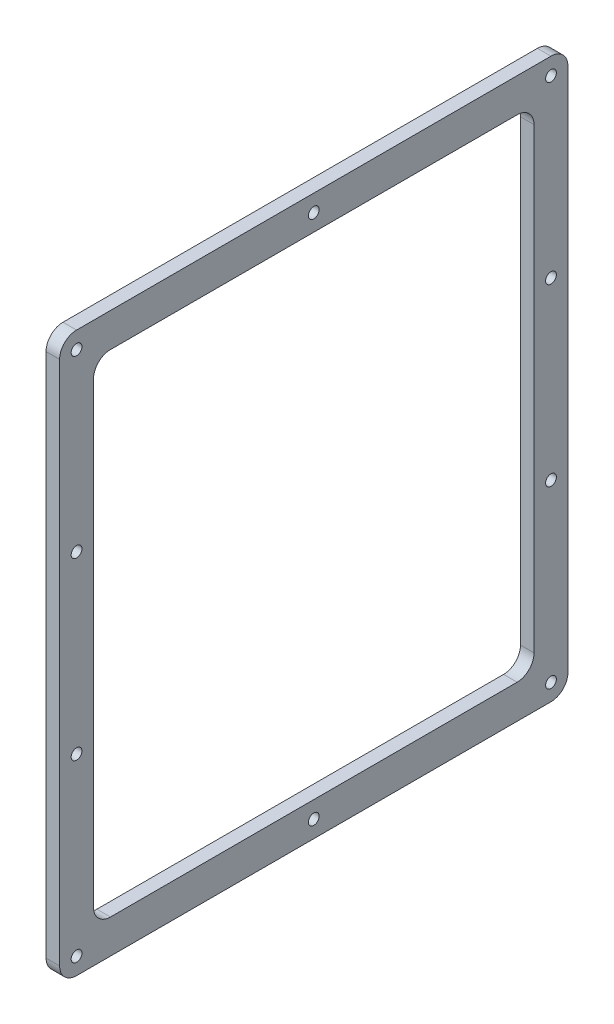
from build123d import *

# Parameters (mm, degrees)
SKETCH1_W              = 190.5
SKETCH1_H              = 209.55
SKETCH1_W_2            = 165.1
SKETCH1_H_2            = 184.15
BOSS_EXTRUDE2_DEPTH    = 5.08
F_10_32_TAPPED_HOLE1_D = 4.0386
FILLET1_R              = 6.35


with BuildPart() as part:
    # Sketch1 → Boss-Extrude2 (new body)
    with BuildSketch(Plane(origin=(0, 0, 0), x_dir=(0, 0, -1), z_dir=(1, 0, 0))):
        with Locations((95.25, 104.775)):
            Rectangle(SKETCH1_W, SKETCH1_H)
        with Locations((95.25, 104.775)):
            Rectangle(SKETCH1_W_2, SKETCH1_H_2, mode=Mode.SUBTRACT)
    extrude(amount=BOSS_EXTRUDE2_DEPTH)

    # #10-32 Tapped Hole1 (through all)
    with Locations(Plane(origin=(5.08, 0, 0), x_dir=(0, 0, -1), z_dir=(1, 0, 0))):
        with Locations((6.35, 203.2), (184.15, 6.35), (6.35, 6.35), (184.15, 203.2), (95.25, 6.35), (95.25, 203.2), (6.35, 137.583333333), (6.35, 71.966666667), (184.15, 71.966666667), (184.15, 137.583333333)):
            Hole(F_10_32_TAPPED_HOLE1_D / 2)

    # Fillet1
    fillet1_edges = [part.edges().sort_by_distance(p)[0] for p in [
        (2.54, 196.85, -12.7),
        (2.54, 12.7, -12.7),
        (2.54, 12.7, -177.8),
        (2.54, 196.85, -177.8),
        (2.54, 209.55, 0),
        (2.54, 209.55, -190.5),
        (2.54, 0, -190.5),
        (2.54, 0, 0),
    ]]
    fillet(fillet1_edges, radius=FILLET1_R)


solid = part.part
